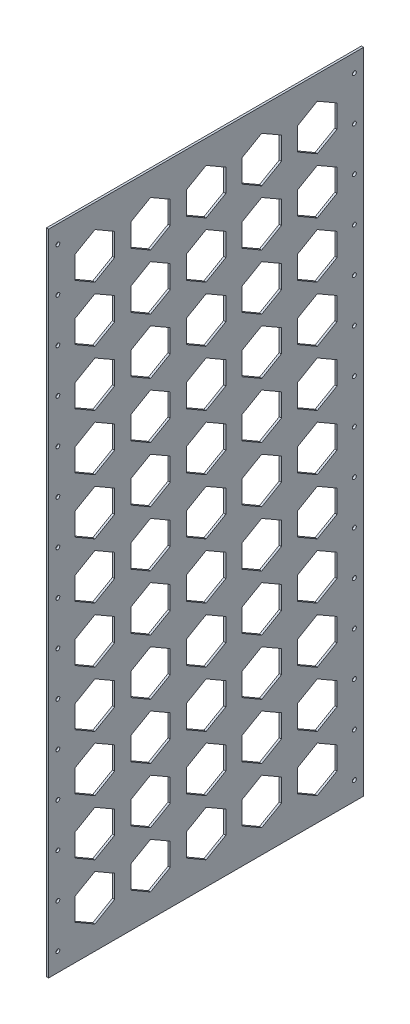
from build123d import *

# Parameters (mm, degrees)
SKETCH1_W           = 431.8
SKETCH1_H           = 889
BOSS_EXTRUDE1_DEPTH = 3
SKETCH2_R           = 2.667
CUT_EXTRUDE1_DEPTH  = 3
CUT_EXTRUDE2_DEPTH  = 3


with BuildPart() as part:
    # Sketch1 → Boss-Extrude1 (new body)
    with BuildSketch(Plane(origin=(0, 0, 0), x_dir=(0, 0, -1), z_dir=(1, 0, 0))):
        with Locations((215.9, 444.5)):
            Rectangle(SKETCH1_W, SKETCH1_H)
    extrude(amount=BOSS_EXTRUDE1_DEPTH)

    # Sketch2 → Cut-Extrude1 (cut)
    with BuildSketch(Plane(origin=(3, 0, 0), x_dir=(0, 0, -1), z_dir=(1, 0, 0))):
        with Locations((12.7, 25.4)):
            Circle(SKETCH2_R)
        with Locations((419.1, 25.4)):
            Circle(SKETCH2_R)
        with Locations((419.1, 85.344)):
            Circle(SKETCH2_R)
        with Locations((419.1, 145.288)):
            Circle(SKETCH2_R)
        with Locations((419.1, 205.232)):
            Circle(SKETCH2_R)
        with Locations((419.1, 265.176)):
            Circle(SKETCH2_R)
        with Locations((419.1, 325.12)):
            Circle(SKETCH2_R)
        with Locations((419.1, 385.064)):
            Circle(SKETCH2_R)
        with Locations((419.1, 445.008)):
            Circle(SKETCH2_R)
        with Locations((419.1, 504.952)):
            Circle(SKETCH2_R)
        with Locations((419.1, 564.896)):
            Circle(SKETCH2_R)
        with Locations((12.7, 85.344)):
            Circle(SKETCH2_R)
        with Locations((12.7, 145.288)):
            Circle(SKETCH2_R)
        with Locations((12.7, 205.232)):
            Circle(SKETCH2_R)
        with Locations((12.7, 265.176)):
            Circle(SKETCH2_R)
        with Locations((12.7, 325.12)):
            Circle(SKETCH2_R)
        with Locations((12.7, 385.064)):
            Circle(SKETCH2_R)
        with Locations((12.7, 445.008)):
            Circle(SKETCH2_R)
        with Locations((12.7, 504.952)):
            Circle(SKETCH2_R)
        with Locations((12.7, 564.896)):
            Circle(SKETCH2_R)
        with Locations((12.7, 624.84)):
            Circle(SKETCH2_R)
        with Locations((419.1, 624.84)):
            Circle(SKETCH2_R)
        with Locations((12.7, 684.784)):
            Circle(SKETCH2_R)
        with Locations((419.1, 684.784)):
            Circle(SKETCH2_R)
        with Locations((12.7, 744.728)):
            Circle(SKETCH2_R)
        with Locations((419.1, 744.728)):
            Circle(SKETCH2_R)
        with Locations((12.7, 804.672)):
            Circle(SKETCH2_R)
        with Locations((419.1, 804.672)):
            Circle(SKETCH2_R)
        with Locations((12.7, 864.616)):
            Circle(SKETCH2_R)
        with Locations((419.1, 864.616)):
            Circle(SKETCH2_R)
    extrude(amount=-CUT_EXTRUDE1_DEPTH, mode=Mode.SUBTRACT)

    # Sketch3 → Cut-Extrude2 (cut)
    with BuildSketch(Plane(origin=(3, 0, 0), x_dir=(0, 0, -1), z_dir=(1, 0, 0))):
        Polygon((112.67058924, 47.894562422), (139.7, 32.289124844), (166.72941076, 47.894562422), (166.72941076, 79.105437578), (139.7, 94.710875156), (112.67058924, 79.105437578), align=None)
        Polygon((36.47058924, 47.894562422), (63.5, 32.289124844), (90.52941076, 47.894562422), (90.52941076, 79.105437578), (63.5, 94.710875156), (36.47058924, 79.105437578), align=None)
        Polygon((188.87058924, 47.894562422), (215.9, 32.289124844), (242.92941076, 47.894562422), (242.92941076, 79.105437578), (215.9, 94.710875156), (188.87058924, 79.105437578), align=None)
        Polygon((265.07058924, 47.894562422), (292.1, 32.289124844), (319.12941076, 47.894562422), (319.12941076, 79.105437578), (292.1, 94.710875156), (265.07058924, 79.105437578), align=None)
        Polygon((341.27058924, 47.894562422), (368.3, 32.289124844), (395.32941076, 47.894562422), (395.32941076, 79.105437578), (368.3, 94.710875156), (341.27058924, 79.105437578), align=None)
        Polygon((112.67058924, 124.094562422), (139.7, 108.489124844), (166.72941076, 124.094562422), (166.72941076, 155.305437578), (139.7, 170.910875156), (112.67058924, 155.305437578), align=None)
        Polygon((188.87058924, 124.094562422), (215.9, 108.489124844), (242.92941076, 124.094562422), (242.92941076, 155.305437578), (215.9, 170.910875156), (188.87058924, 155.305437578), align=None)
        Polygon((265.07058924, 124.094562422), (292.1, 108.489124844), (319.12941076, 124.094562422), (319.12941076, 155.305437578), (292.1, 170.910875156), (265.07058924, 155.305437578), align=None)
        Polygon((341.27058924, 124.094562422), (368.3, 108.489124844), (395.32941076, 124.094562422), (395.32941076, 155.305437578), (368.3, 170.910875156), (341.27058924, 155.305437578), align=None)
        Polygon((112.67058924, 200.294562422), (139.7, 184.689124844), (166.72941076, 200.294562422), (166.72941076, 231.505437578), (139.7, 247.110875156), (112.67058924, 231.505437578), align=None)
        Polygon((188.87058924, 200.294562422), (215.9, 184.689124844), (242.92941076, 200.294562422), (242.92941076, 231.505437578), (215.9, 247.110875156), (188.87058924, 231.505437578), align=None)
        Polygon((265.07058924, 200.294562422), (292.1, 184.689124844), (319.12941076, 200.294562422), (319.12941076, 231.505437578), (292.1, 247.110875156), (265.07058924, 231.505437578), align=None)
        Polygon((341.27058924, 200.294562422), (368.3, 184.689124844), (395.32941076, 200.294562422), (395.32941076, 231.505437578), (368.3, 247.110875156), (341.27058924, 231.505437578), align=None)
        Polygon((112.67058924, 276.494562422), (139.7, 260.889124844), (166.72941076, 276.494562422), (166.72941076, 307.705437578), (139.7, 323.310875156), (112.67058924, 307.705437578), align=None)
        Polygon((188.87058924, 276.494562422), (215.9, 260.889124844), (242.92941076, 276.494562422), (242.92941076, 307.705437578), (215.9, 323.310875156), (188.87058924, 307.705437578), align=None)
        Polygon((265.07058924, 276.494562422), (292.1, 260.889124844), (319.12941076, 276.494562422), (319.12941076, 307.705437578), (292.1, 323.310875156), (265.07058924, 307.705437578), align=None)
        Polygon((341.27058924, 276.494562422), (368.3, 260.889124844), (395.32941076, 276.494562422), (395.32941076, 307.705437578), (368.3, 323.310875156), (341.27058924, 307.705437578), align=None)
        Polygon((112.67058924, 352.694562422), (139.7, 337.089124844), (166.72941076, 352.694562422), (166.72941076, 383.905437578), (139.7, 399.510875156), (112.67058924, 383.905437578), align=None)
        Polygon((188.87058924, 352.694562422), (215.9, 337.089124844), (242.92941076, 352.694562422), (242.92941076, 383.905437578), (215.9, 399.510875156), (188.87058924, 383.905437578), align=None)
        Polygon((265.07058924, 352.694562422), (292.1, 337.089124844), (319.12941076, 352.694562422), (319.12941076, 383.905437578), (292.1, 399.510875156), (265.07058924, 383.905437578), align=None)
        Polygon((341.27058924, 352.694562422), (368.3, 337.089124844), (395.32941076, 352.694562422), (395.32941076, 383.905437578), (368.3, 399.510875156), (341.27058924, 383.905437578), align=None)
        Polygon((112.67058924, 428.894562422), (139.7, 413.289124844), (166.72941076, 428.894562422), (166.72941076, 460.105437578), (139.7, 475.710875156), (112.67058924, 460.105437578), align=None)
        Polygon((188.87058924, 428.894562422), (215.9, 413.289124844), (242.92941076, 428.894562422), (242.92941076, 460.105437578), (215.9, 475.710875156), (188.87058924, 460.105437578), align=None)
        Polygon((265.07058924, 428.894562422), (292.1, 413.289124844), (319.12941076, 428.894562422), (319.12941076, 460.105437578), (292.1, 475.710875156), (265.07058924, 460.105437578), align=None)
        Polygon((341.27058924, 428.894562422), (368.3, 413.289124844), (395.32941076, 428.894562422), (395.32941076, 460.105437578), (368.3, 475.710875156), (341.27058924, 460.105437578), align=None)
        Polygon((112.67058924, 505.094562422), (139.7, 489.489124844), (166.72941076, 505.094562422), (166.72941076, 536.305437578), (139.7, 551.910875156), (112.67058924, 536.305437578), align=None)
        Polygon((188.87058924, 505.094562422), (215.9, 489.489124844), (242.92941076, 505.094562422), (242.92941076, 536.305437578), (215.9, 551.910875156), (188.87058924, 536.305437578), align=None)
        Polygon((265.07058924, 505.094562422), (292.1, 489.489124844), (319.12941076, 505.094562422), (319.12941076, 536.305437578), (292.1, 551.910875156), (265.07058924, 536.305437578), align=None)
        Polygon((341.27058924, 505.094562422), (368.3, 489.489124844), (395.32941076, 505.094562422), (395.32941076, 536.305437578), (368.3, 551.910875156), (341.27058924, 536.305437578), align=None)
        Polygon((112.67058924, 581.294562422), (139.7, 565.689124844), (166.72941076, 581.294562422), (166.72941076, 612.505437578), (139.7, 628.110875156), (112.67058924, 612.505437578), align=None)
        Polygon((188.87058924, 581.294562422), (215.9, 565.689124844), (242.92941076, 581.294562422), (242.92941076, 612.505437578), (215.9, 628.110875156), (188.87058924, 612.505437578), align=None)
        Polygon((265.07058924, 581.294562422), (292.1, 565.689124844), (319.12941076, 581.294562422), (319.12941076, 612.505437578), (292.1, 628.110875156), (265.07058924, 612.505437578), align=None)
        Polygon((341.27058924, 581.294562422), (368.3, 565.689124844), (395.32941076, 581.294562422), (395.32941076, 612.505437578), (368.3, 628.110875156), (341.27058924, 612.505437578), align=None)
        Polygon((112.67058924, 657.494562422), (139.7, 641.889124844), (166.72941076, 657.494562422), (166.72941076, 688.705437578), (139.7, 704.310875156), (112.67058924, 688.705437578), align=None)
        Polygon((188.87058924, 657.494562422), (215.9, 641.889124844), (242.92941076, 657.494562422), (242.92941076, 688.705437578), (215.9, 704.310875156), (188.87058924, 688.705437578), align=None)
        Polygon((265.07058924, 657.494562422), (292.1, 641.889124844), (319.12941076, 657.494562422), (319.12941076, 688.705437578), (292.1, 704.310875156), (265.07058924, 688.705437578), align=None)
        Polygon((341.27058924, 657.494562422), (368.3, 641.889124844), (395.32941076, 657.494562422), (395.32941076, 688.705437578), (368.3, 704.310875156), (341.27058924, 688.705437578), align=None)
        Polygon((112.67058924, 733.694562422), (139.7, 718.089124844), (166.72941076, 733.694562422), (166.72941076, 764.905437578), (139.7, 780.510875156), (112.67058924, 764.905437578), align=None)
        Polygon((188.87058924, 733.694562422), (215.9, 718.089124844), (242.92941076, 733.694562422), (242.92941076, 764.905437578), (215.9, 780.510875156), (188.87058924, 764.905437578), align=None)
        Polygon((265.07058924, 733.694562422), (292.1, 718.089124844), (319.12941076, 733.694562422), (319.12941076, 764.905437578), (292.1, 780.510875156), (265.07058924, 764.905437578), align=None)
        Polygon((341.27058924, 733.694562422), (368.3, 718.089124844), (395.32941076, 733.694562422), (395.32941076, 764.905437578), (368.3, 780.510875156), (341.27058924, 764.905437578), align=None)
        Polygon((112.67058924, 809.894562422), (139.7, 794.289124844), (166.72941076, 809.894562422), (166.72941076, 841.105437578), (139.7, 856.710875156), (112.67058924, 841.105437578), align=None)
        Polygon((188.87058924, 809.894562422), (215.9, 794.289124844), (242.92941076, 809.894562422), (242.92941076, 841.105437578), (215.9, 856.710875156), (188.87058924, 841.105437578), align=None)
        Polygon((265.07058924, 809.894562422), (292.1, 794.289124844), (319.12941076, 809.894562422), (319.12941076, 841.105437578), (292.1, 856.710875156), (265.07058924, 841.105437578), align=None)
        Polygon((341.27058924, 809.894562422), (368.3, 794.289124844), (395.32941076, 809.894562422), (395.32941076, 841.105437578), (368.3, 856.710875156), (341.27058924, 841.105437578), align=None)
        Polygon((36.47058924, 124.094562422), (63.5, 108.489124844), (90.52941076, 124.094562422), (90.52941076, 155.305437578), (63.5, 170.910875156), (36.47058924, 155.305437578), align=None)
        Polygon((36.47058924, 200.294562422), (63.5, 184.689124844), (90.52941076, 200.294562422), (90.52941076, 231.505437578), (63.5, 247.110875156), (36.47058924, 231.505437578), align=None)
        Polygon((36.47058924, 276.494562422), (63.5, 260.889124844), (90.52941076, 276.494562422), (90.52941076, 307.705437578), (63.5, 323.310875156), (36.47058924, 307.705437578), align=None)
        Polygon((36.47058924, 352.694562422), (63.5, 337.089124844), (90.52941076, 352.694562422), (90.52941076, 383.905437578), (63.5, 399.510875156), (36.47058924, 383.905437578), align=None)
        Polygon((36.47058924, 428.894562422), (63.5, 413.289124844), (90.52941076, 428.894562422), (90.52941076, 460.105437578), (63.5, 475.710875156), (36.47058924, 460.105437578), align=None)
        Polygon((36.47058924, 505.094562422), (63.5, 489.489124844), (90.52941076, 505.094562422), (90.52941076, 536.305437578), (63.5, 551.910875156), (36.47058924, 536.305437578), align=None)
        Polygon((36.47058924, 581.294562422), (63.5, 565.689124844), (90.52941076, 581.294562422), (90.52941076, 612.505437578), (63.5, 628.110875156), (36.47058924, 612.505437578), align=None)
        Polygon((36.47058924, 657.494562422), (63.5, 641.889124844), (90.52941076, 657.494562422), (90.52941076, 688.705437578), (63.5, 704.310875156), (36.47058924, 688.705437578), align=None)
        Polygon((36.47058924, 733.694562422), (63.5, 718.089124844), (90.52941076, 733.694562422), (90.52941076, 764.905437578), (63.5, 780.510875156), (36.47058924, 764.905437578), align=None)
        Polygon((36.47058924, 809.894562422), (63.5, 794.289124844), (90.52941076, 809.894562422), (90.52941076, 841.105437578), (63.5, 856.710875156), (36.47058924, 841.105437578), align=None)
    extrude(amount=-CUT_EXTRUDE2_DEPTH, mode=Mode.SUBTRACT)


solid = part.part
